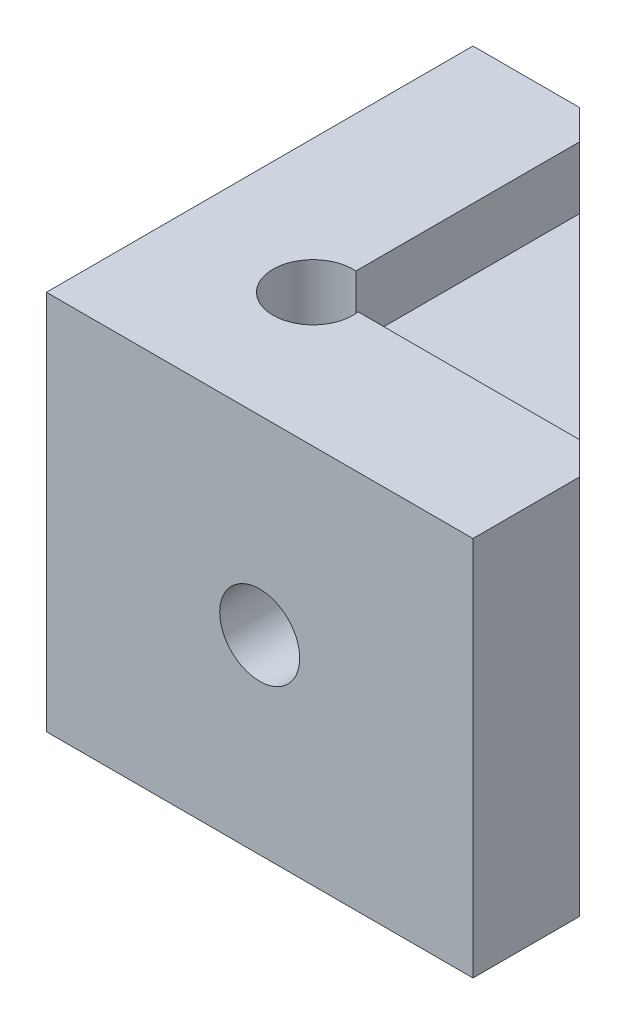
from build123d import *

# Parameters (mm, degrees)
MAIN_BODY_DEPTH              = 34
SKETCH3_R                    = 3.571875
F_9_32_RIGHT_RAIL_DEPTH      = 1
F_9_32_RIGHT_RAIL_DEPTH_BACK = 5.55625
SKETCH4_R                    = 3.571875
F_9_32_LEFT_RAIL_DEPTH       = 5.55625
SKETCH8_R                    = 3.571875
F_9_32_TOPPER_DEPTH          = 1
F_9_32_TOPPER_DEPTH_BACK     = 35
CUT_EXTRUDE3_START           = -5.55625
CUT_EXTRUDE3_DEPTH           = 32.54375
CUT_EXTRUDE4_START           = -5.55625
CUT_EXTRUDE4_DEPTH           = 32.54375
CUT_EXTRUDE6_DEPTH           = 5.55625


with BuildPart() as part:
    # Sketch1 → Main Body (new body)
    with BuildSketch(Plane(origin=(0, 0, 0), x_dir=(1, 0, 0), z_dir=(0, 1, 0))):
        Polygon((0, 0), (38.1, 0), (38.1, 9.525), (9.525, 38.1), (0, 38.1), align=None)
    extrude(amount=MAIN_BODY_DEPTH)

    # Sketch3 → 9/32 Right Rail (cut, two sides)
    with BuildSketch(Plane.XY) as f_9_32_right_rail_sk:
        with Locations((19.05, 17)):
            Circle(SKETCH3_R)
    extrude(amount=F_9_32_RIGHT_RAIL_DEPTH, mode=Mode.SUBTRACT)
    extrude(f_9_32_right_rail_sk.sketch, amount=-F_9_32_RIGHT_RAIL_DEPTH_BACK, mode=Mode.SUBTRACT)

    # Sketch4 → 9/32 Left Rail (cut)
    with BuildSketch(Plane.ZY):
        with Locations((-19.05, 17)):
            Circle(SKETCH4_R)
    extrude(amount=-F_9_32_LEFT_RAIL_DEPTH, mode=Mode.SUBTRACT)

    # Sketch8 → 9/32 Topper (cut, two sides)
    with BuildSketch(Plane(origin=(0, 34, 0), x_dir=(1, 0, 0), z_dir=(0, 1, 0))) as f_9_32_topper_sk:
        with Locations((11.90625, 11.90625)):
            Circle(SKETCH8_R)
    extrude(amount=F_9_32_TOPPER_DEPTH, mode=Mode.SUBTRACT)
    extrude(f_9_32_topper_sk.sketch, amount=-F_9_32_TOPPER_DEPTH_BACK, mode=Mode.SUBTRACT)

    # Sketch9 → Cut-Extrude3 (cut)
    with BuildSketch(Plane.ZY.offset(CUT_EXTRUDE3_START)):
        Polygon((-22.372470377, 22.7546875), (-25.694940754, 17), (-22.372470377, 11.2453125), (-15.727529623, 11.2453125), (-12.405059246, 17), (-15.727529623, 22.7546875), align=None)
    extrude(amount=-CUT_EXTRUDE3_DEPTH, mode=Mode.SUBTRACT)

    # Sketch10 → Cut-Extrude4 (cut)
    with BuildSketch(Plane.XY.offset(CUT_EXTRUDE4_START)):
        Polygon((15.612961679, 22.953125), (12.175923357, 17), (15.612961679, 11.046875), (22.487038321, 11.046875), (25.924076643, 17), (22.487038321, 22.953125), align=None)
    extrude(amount=-CUT_EXTRUDE4_DEPTH, mode=Mode.SUBTRACT)

    # Sketch13 → Cut-Extrude6 (cut)
    with BuildSketch(Plane(origin=(0, 34, 0), x_dir=(1, 0, 0), z_dir=(0, 1, 0))):
        Polygon((35.219940754, 12.405059246), (12.175923357, 12.405059246), (12.175923357, 35.449076643), align=None)
    extrude(amount=-CUT_EXTRUDE6_DEPTH, mode=Mode.SUBTRACT)


solid = part.part
